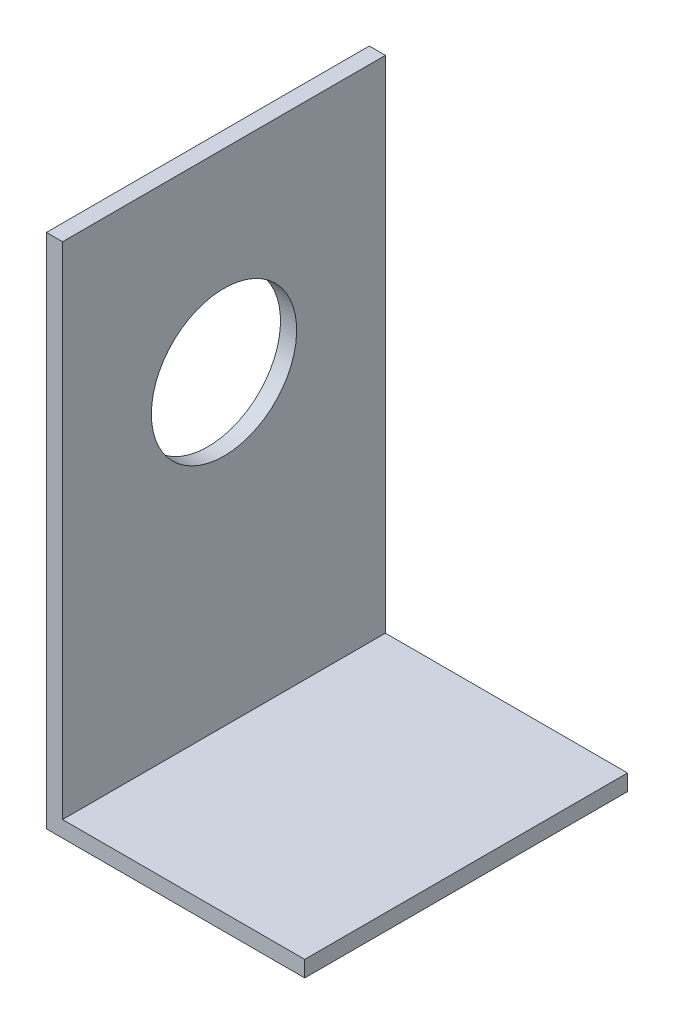
from build123d import *

# Parameters (mm, degrees)
BOSS_EXTRUDE1_DEPTH = 63.5
SKETCH2_R           = 14.2875
CUT_EXTRUDE1_DEPTH  = 51.8


with BuildPart() as part:
    # Sketch1 → Boss-Extrude1 (new body)
    with BuildSketch(Plane.XY):
        Polygon((0, 0), (0, 101.6), (3.175, 101.6), (3.175, 3.175), (50.8, 3.175), (50.8, 0), align=None)
    extrude(amount=BOSS_EXTRUDE1_DEPTH)

    # Sketch2 → Cut-Extrude1 (cut, through all)
    with BuildSketch(Plane.ZY):
        with Locations((31.75, 63.5)):
            Circle(SKETCH2_R)
    extrude(amount=-CUT_EXTRUDE1_DEPTH, mode=Mode.SUBTRACT)


solid = part.part
